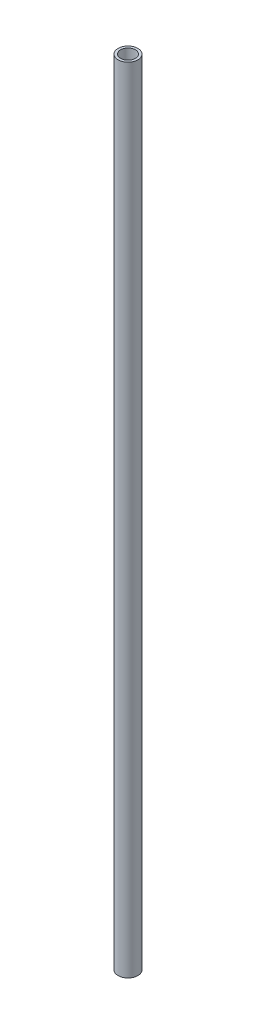
from build123d import *

# Parameters (mm, degrees)
SKETCH3_R           = 12.7
BOSS_EXTRUDE1_DEPTH = 1016
SHELL1_T            = -3.175


with BuildPart() as part:
    # Sketch3 → Boss-Extrude1 (new body)
    with BuildSketch(Plane(origin=(0, 0, 0), x_dir=(1, 0, 0), z_dir=(0, 1, 0))):
        with Locations(Location((0, 0, 0), (0, 0, 270))):
            Circle(SKETCH3_R)
    extrude(amount=BOSS_EXTRUDE1_DEPTH)

    # Shell1
    shell1_openings = [part.faces().sort_by_distance(p)[0] for p in [
        (0, 1016, 0),
        (0, 0, 0),
    ]]
    offset(amount=SHELL1_T, openings=shell1_openings, kind=Kind.INTERSECTION)


solid = part.part
